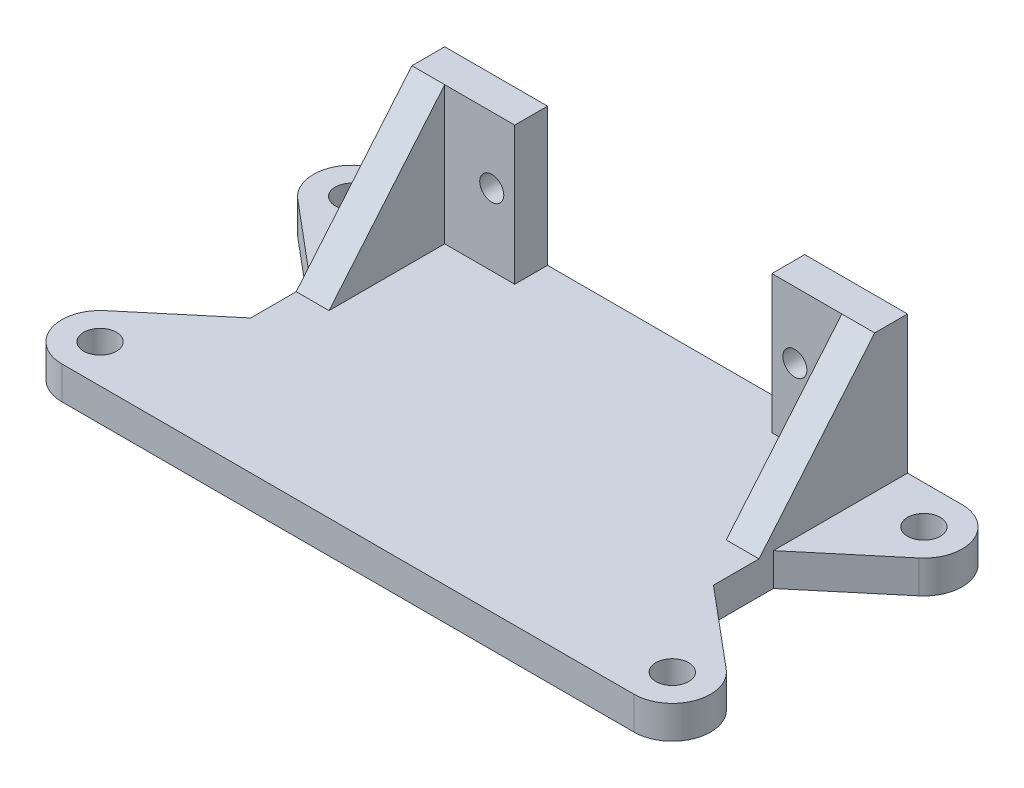
from build123d import *

# Parameters (mm, degrees)
BOSS_EXTRUDE1_DEPTH     = 3
SKETCH3_W               = 42.3
SKETCH3_H               = 30
BOSS_EXTRUDE2_DEPTH     = 3
SKETCH4_R               = 1.1
CUT_EXTRUDE1_DEPTH      = 4
BOSS_EXTRUDE3_DEPTH     = 3
BOSS_EXTRUDE4_START     = -3
SKETCH6_R               = 1.5
BOSS_EXTRUDE4_DEPTH     = 3
MIRROR3_START           = -3
MIRROR3_COPY_1_SKETCH_R = 1.5
MIRROR3_COPY_1_DEPTH    = 3


with BuildPart() as part:
    # Sketch2 → Boss-Extrude1 (new body)
    with BuildSketch(Plane.XY):
        Polygon((-11.75, 3), (11.75, 3), (11.75, 15.6), (21.15, 15.6), (21.15, 0), (-21.15, 0), (-21.15, 15.6), (-11.75, 15.6), align=None)
    extrude(amount=BOSS_EXTRUDE1_DEPTH)

    # Sketch3 → Boss-Extrude2 (add)
    with BuildSketch(Plane.XZ):
        with Locations((0, 15)):
            Rectangle(SKETCH3_W, SKETCH3_H)
    extrude(amount=-BOSS_EXTRUDE2_DEPTH)

    # Sketch4 → Cut-Extrude1 (cut, through all)
    with BuildSketch(Plane.XY.offset(3)):
        with Locations((13.85, 9.55)):
            Circle(SKETCH4_R)
        with Locations((-13.85, 9.55)):
            Circle(SKETCH4_R)
    extrude(amount=-CUT_EXTRUDE1_DEPTH, mode=Mode.SUBTRACT)

    # Sketch5 → Boss-Extrude3 (add)
    with BuildSketch(Plane(origin=(21.15, 0, 0), x_dir=(0, 0, -1), z_dir=(1, 0, 0))):
        Polygon((-3, 15.6), (-13.572655353, 3), (-3, 3), align=None)
    boss_extrude3 = extrude(amount=-BOSS_EXTRUDE3_DEPTH)

    # Mirror1: Boss-Extrude3 across plane
    add(boss_extrude3.mirror(Plane(origin=(0, 0, 0), x_dir=(0, 0, 1), z_dir=(1, 0, 0))))

    # Sketch6 → Boss-Extrude4 (add)
    with BuildSketch(Plane.XZ.offset(BOSS_EXTRUDE4_START)):
        with BuildLine():
            Line((-21.15, 30), (-26.15, 30))
            ThreePointArc((-26.15, 30), (-29.438924173, 27.697070502), (-28.399756634, 23.818844449))
            Line((-28.399756634, 23.818844449), (-21.15, 17.735576331))
            Line((-21.15, 17.735576331), (-21.15, 30))
        make_face()
        with Locations((-26.15, 26.5)):
            Circle(SKETCH6_R, mode=Mode.SUBTRACT)
    boss_extrude4 = extrude(amount=BOSS_EXTRUDE4_DEPTH)

    # Mirror2: Boss-Extrude4 across plane
    add(boss_extrude4.mirror(Plane.XY.offset(15)))

    # Mirror3: Boss-Extrude4 across plane
    add(boss_extrude4.mirror(Plane(origin=(0, 0, 0), x_dir=(0, 0, 1), z_dir=(1, 0, 0))))

    # Mirror3 copy 1 sketch → Mirror3 copy 1 (add)
    with BuildSketch(Plane(origin=(0, 0, 30), x_dir=(-1, 0, 0), z_dir=(0, -1, 0)).offset(MIRROR3_START)):
        with BuildLine():
            Line((-21.15, 30), (-26.15, 30))
            ThreePointArc((-26.15, 30), (-29.438924173, 27.697070502), (-28.399756634, 23.818844449))
            Line((-28.399756634, 23.818844449), (-21.15, 17.735576331))
            Line((-21.15, 17.735576331), (-21.15, 30))
        make_face()
        with Locations((-26.15, 26.5)):
            Circle(MIRROR3_COPY_1_SKETCH_R, mode=Mode.SUBTRACT)
    extrude(amount=MIRROR3_COPY_1_DEPTH)


solid = part.part
